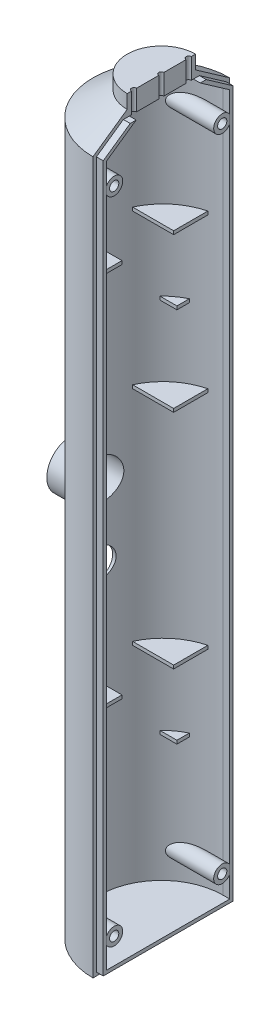
from build123d import *
from build123d.topology import SkipClean

# Parameters (mm, degrees)
SKETCH_2_W             = 24.01358344
SKETCH_2_H             = 47.818963435
CUT_EXTRUDE_1_DEPTH    = 242
SHELL_1_T              = -2
EXTRUDE_1_DEPTH        = 2
EXTRUDE_2_DEPTH        = 1
EXTRUDE_2_2_DEPTH      = 1
EXTRUDE_7_REACH        = 219.046
SKETCH_6_R             = 2.5
SKETCH_6_R_2           = 1.35
PATTERN_LINEAR_1_COUNT = 2
PATTERN_LINEAR_1_PITCH = 190
SKETCH_8_W             = 16
SKETCH_8_H             = 35
CUT_EXTRUDE_3_DEPTH    = 1.5
SKETCH_9_R             = 6
SKETCH_9_R_2           = 4.25
SKETCH_9_R_3           = 1.5
CUT_EXTRUDE_4_DEPTH    = 4
EXTRUDE_8_DEPTH        = 4
SKETCH_11_R            = 0.75
CUT_EXTRUDE_5_DEPTH    = 6
EXTRUDE_9_DEPTH        = 1
PATTERN_LINEAR_2_COUNT = 2
PATTERN_LINEAR_2_PITCH = 110
SKETCH_13_R            = 7
SKETCH_13_R_2          = 6
EXTRUDE_10_DEPTH       = 8
PATTERN_LINEAR_5_COUNT = 2
PATTERN_LINEAR_5_PITCH = 110
PATTERN_LINEAR_6_COUNT = 2
PATTERN_LINEAR_6_PITCH = 65


with BuildPart() as part:
    # 草图1 → 旋转1 (revolve)
    with BuildSketch(Plane.XY, mode=Mode.PRIVATE) as revolve_1_sk:
        Polygon((0, 0), (10, 0), (20, -7), (20, -215), (0, -215), align=None)
    revolve(revolve_1_sk.sketch.rotate(Axis((0, 0, 0), (0, -1, 0)), 180), axis=Axis((0, 0, 0), (0, -1, 0)))

    # 草图2 → 切除-拉伸1 (cut)
    with BuildSketch(Plane(origin=(0, 0, 0), x_dir=(1, 0, 0), z_dir=(0, 1, 0))):
        with Locations((12.00679172, 0.185423962)):
            Rectangle(SKETCH_2_W, SKETCH_2_H)
    extrude(amount=-CUT_EXTRUDE_1_DEPTH, mode=Mode.SUBTRACT)

    # 抽壳1
    shell_1_openings = [part.faces().sort_by_distance(p)[0] for p in [
        (0, -108.363032435, 0),
    ]]
    offset(amount=SHELL_1_T, openings=shell_1_openings)

    # 草图3 → 凸台-拉伸1 (add)
    with BuildSketch(Plane(origin=(0, 0, 0), x_dir=(0, 0, -1), z_dir=(1, 0, 0))):
        Polygon((-9.369555538, -2), (-11.113349198, -2), (-19, -7.520655562), (-19, -214), (19, -214), (19, -7.520655562), (11.113349198, -2), (9.369555538, -2), (18, -8.041311123), (18, -213), (-18, -213), (-18, -8.041311123), align=None)
    extrude(amount=EXTRUDE_1_DEPTH)


with BuildPart() as body_2:
    # 草图4 → 凸台-拉伸2 (new body)
    with BuildSketch(Plane(origin=(0, -152.5, 0), x_dir=(1, 0, 0), z_dir=(0, 1, 0))):
        with BuildLine():
            Line((-3.964663289, 17.557945353), (-3.964663289, 7.557945353))
            Line((-3.964663289, 7.557945353), (-15.964663289, 7.557945353))
            ThreePointArc((-15.964663289, 7.557945353), (-11.097780731, 13.917686283), (-3.964663289, 17.557945353))
        make_face()
    extrude(amount=EXTRUDE_2_DEPTH)


with BuildPart() as body_3:
    # 草图4 → Extrude 2 2 (new body)
    with BuildSketch(Plane(origin=(0, -152.5, 0), x_dir=(1, 0, 0), z_dir=(0, 1, 0))):
        with BuildLine():
            Line((-3.964663289, -17.557945353), (-3.964663289, -7.557945353))
            Line((-3.964663289, -7.557945353), (-15.964663289, -7.557945353))
            ThreePointArc((-15.964663289, -7.557945353), (-11.097780731, -13.917686283), (-3.964663289, -17.557945353))
        make_face()
    extrude(amount=EXTRUDE_2_2_DEPTH)


with BuildPart() as body_4:

    # 草图6 → 凸台-拉伸7 (new, up to next)
    with BuildSketch(Plane(origin=(2, 0, 0), x_dir=(0, 0, -1), z_dir=(1, 0, 0)), mode=Mode.PRIVATE) as extrude_7_sk1:
        with Locations((15.8, -205.5)):
            Circle(SKETCH_6_R)
        with Locations(Location((15.8, -205.5, 0), (0, 0, 90))):
            Circle(SKETCH_6_R_2, mode=Mode.SUBTRACT)
    extrude_7_tool1 = extrude(extrude_7_sk1.sketch, amount=-EXTRUDE_7_REACH, mode=Mode.PRIVATE) - part.part
    # 草图6 → 凸台-拉伸7 (new, up to next)
    with BuildSketch(Plane(origin=(2, 0, 0), x_dir=(0, 0, -1), z_dir=(1, 0, 0)), mode=Mode.PRIVATE) as extrude_7_sk2:
        with Locations((-15.8, -205.5)):
            Circle(SKETCH_6_R)
        with Locations(Location((-15.8, -205.5, 0), (0, 0, 90))):
            Circle(SKETCH_6_R_2, mode=Mode.SUBTRACT)
    extrude_7_tool2 = extrude(extrude_7_sk2.sketch, amount=-EXTRUDE_7_REACH, mode=Mode.PRIVATE) - part.part
    extrude_7_1 = extrude_7_tool1.solids().sort_by_distance((2, -205.5, -13.370711))[0]
    add(extrude_7_1)
    extrude_7_2 = extrude_7_tool2.solids().sort_by_distance((2, -205.5, 18.229289))[0]
    add(extrude_7_2)
    extrude_7 = extrude_7_1 + extrude_7_2  # 凸台-拉伸7 as one shape, for the pattern or mirror that repeats it


with BuildPart() as pattern_linear_1_1:
    # 阵列(线性)1: 凸台-拉伸7 ×2
    with Locations(*[(0, i * PATTERN_LINEAR_1_PITCH, 0) for i in range(1, PATTERN_LINEAR_1_COUNT)]):
        add(extrude_7)


with BuildPart() as part_1:
    add(part.part)

    # 草图8 → 切除-拉伸3 (cut)
    with BuildSketch(Plane(origin=(-20, 0, 0), x_dir=(0, 0, -1), z_dir=(1, 0, 0))):
        with Locations((0, -117.5)):
            Rectangle(SKETCH_8_W, SKETCH_8_H)
    extrude(amount=CUT_EXTRUDE_3_DEPTH, mode=Mode.SUBTRACT)

    # 草图9 → 切除-拉伸4 (cut)
    with SkipClean():  # the faces are left unmerged after this step: merging them gives an invalid solid
        with BuildSketch(Plane.ZY.offset(18.5)):
            with Locations(Location((0, -108, 0), (0, 0, 270))):
                Circle(SKETCH_9_R)
            with Locations(Location((0, -129, 0), (0, 0, 270))):
                Circle(SKETCH_9_R_2)
            with Locations(Location((0, -119, 0), (0, 0, 270))):
                Circle(SKETCH_9_R_3)
        extrude(amount=-CUT_EXTRUDE_4_DEPTH, mode=Mode.SUBTRACT)

    # 草图10 → 凸台-拉伸8 (add)
    with SkipClean():  # the faces are left unmerged after this step: merging them gives an invalid solid
        with BuildSketch(Plane(origin=(0, 0, 0), x_dir=(1, 0, 0), z_dir=(0, 1, 0))):
            with BuildLine():
                Line((0, 10), (0, -10))
                ThreePointArc((0, -10), (-10, 0), (0, 10))
            make_face()
        extrude(amount=EXTRUDE_8_DEPTH)

    # 草图11 → 切除-拉伸5 (cut)
    with SkipClean():  # the faces are left unmerged after this step: merging them gives an invalid solid
        with BuildSketch(Plane(origin=(0, 4, 0), x_dir=(1, 0, 0), z_dir=(0, 1, 0))):
            Circle(SKETCH_11_R)
            with Locations((0, 8)):
                Circle(SKETCH_11_R)
            with Locations((0, -8)):
                Circle(SKETCH_11_R)
        extrude(amount=-CUT_EXTRUDE_5_DEPTH, mode=Mode.SUBTRACT)

    # 草图12 → 凸台-拉伸9 (add)
    with SkipClean():  # the faces are left unmerged after this step: merging them gives an invalid solid
        with BuildSketch(Plane(origin=(0, -65, 0), x_dir=(-1, 0, 0), z_dir=(0, -1, 0))):
            with BuildLine():
                Line((7.951833847, 12.5), (12.951833847, 12.5))
                ThreePointArc((12.951833847, 12.5), (11.417788353, 15.71809821), (7.951833847, 16.552730482))
                Line((7.951833847, 16.552730482), (7.951833847, 12.5))
            make_face()
            with BuildLine():
                Line((7.951833847, -12.5), (12.951833847, -12.5))
                ThreePointArc((12.951833847, -12.5), (11.019574927, -15.076247576), (7.951833847, -16.055860139))
                Line((7.951833847, -16.055860139), (7.951833847, -12.5))
            make_face()
        extrude_9 = extrude(amount=EXTRUDE_9_DEPTH)

    # 阵列(线性)2: 凸台-拉伸9 ×2
    with SkipClean():  # the faces are left unmerged after this step: merging them gives an invalid solid
        with Locations(*[(0, -i * PATTERN_LINEAR_2_PITCH, 0) for i in range(1, PATTERN_LINEAR_2_COUNT)]):
            add(extrude_9)

    # 草图13 → 凸台-拉伸10 (add)
    with SkipClean():  # the faces are left unmerged after this step: merging them gives an invalid solid
        with BuildSketch(Plane.ZY.offset(18.5)):
            with Locations(Location((0, -108, 0), (0, 0, 270))):
                Circle(SKETCH_13_R)
            with Locations(Location((0, -108, 0), (0, 0, 270))):
                Circle(SKETCH_13_R_2, mode=Mode.SUBTRACT)
        extrude(amount=EXTRUDE_10_DEPTH)


with BuildPart() as pattern_linear_5_1:
    # 阵列(线性)5: pattern copy
    add(body_2.part.moved(Location(Vector(0, 1, 0) * (1 * PATTERN_LINEAR_5_PITCH))))


with BuildPart() as pattern_linear_5_2:
    # 阵列(线性)5: pattern copy
    add(body_3.part.moved(Location(Vector(0, 1, 0) * (1 * PATTERN_LINEAR_5_PITCH))))


with BuildPart() as pattern_linear_6_1:
    # 阵列(线性)6: pattern copy
    add(body_2.part.moved(Location(Vector(0, 1, 0) * (1 * PATTERN_LINEAR_6_PITCH))))


solid = Compound([body_2.part, body_3.part, body_4.part, pattern_linear_1_1.part, part_1.part, pattern_linear_5_1.part, pattern_linear_5_2.part, pattern_linear_6_1.part])
